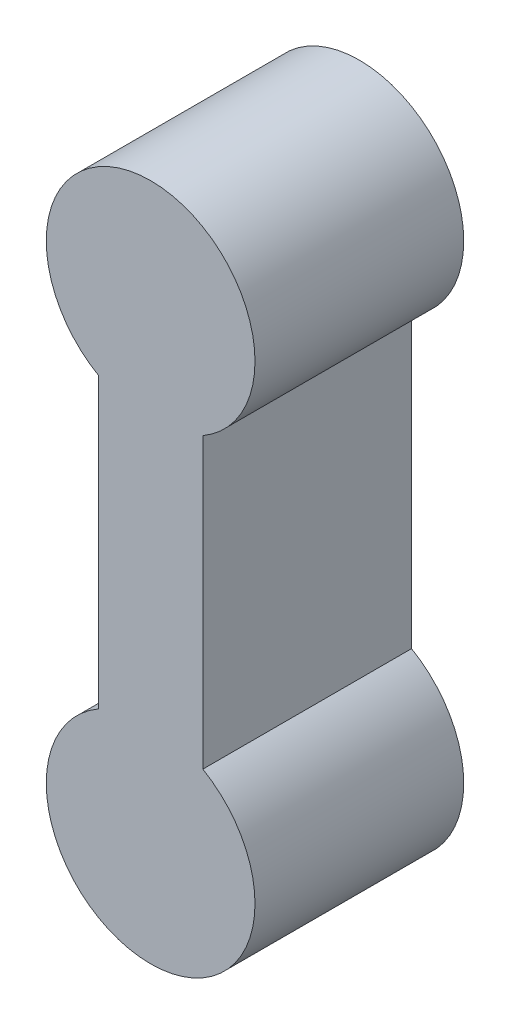
from build123d import *

# Parameters (mm, degrees)
EXTRUDE_1_DEPTH = 2


with BuildPart() as part:
    # 草图1 → 凸台-拉伸1 (new body)
    with BuildSketch(Plane.XY):
        with BuildLine():
            Line((-0.5, -1.383974596), (-0.5, 1.383974596))
            ThreePointArc((-0.5, 1.383974596), (0, 3.25), (0.5, 1.383974596))
            Line((0.5, 1.383974596), (0.5, -1.383974596))
            ThreePointArc((0.5, -1.383974596), (0, -3.25), (-0.5, -1.383974596))
        make_face()
    extrude(amount=EXTRUDE_1_DEPTH)


solid = part.part
